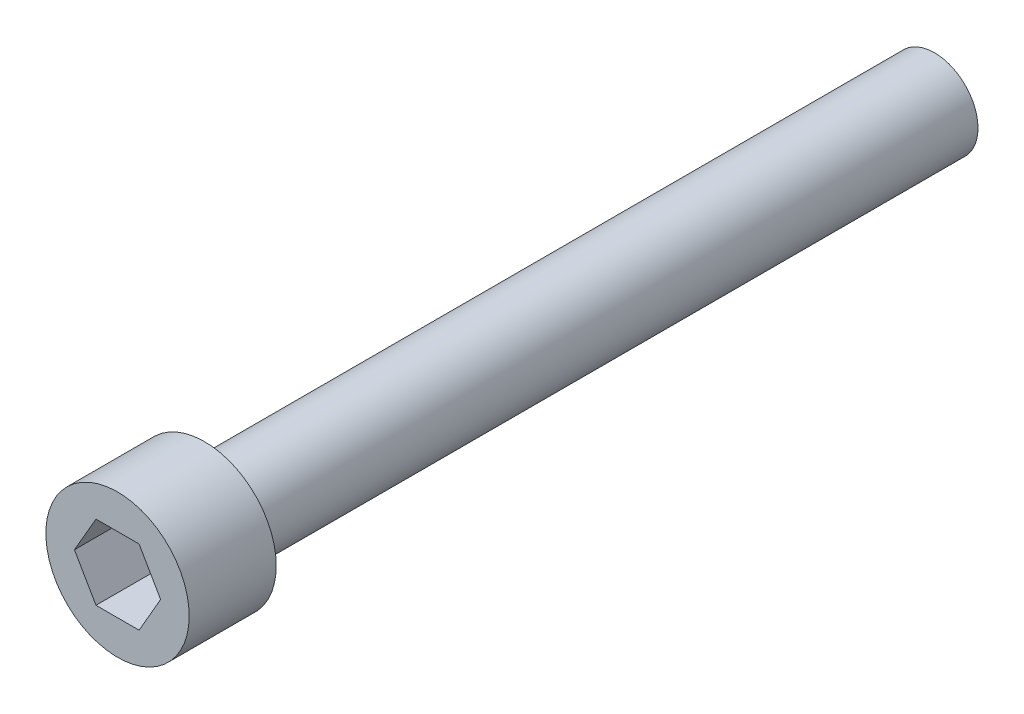
from build123d import *

# Parameters (mm, degrees)
F_9_64_ALLEN_DEPTH = 3.175


with BuildPart() as part:
    # Sketch1 → Revolve1 (revolve)
    with BuildSketch(Plane(origin=(0, 0, 0), x_dir=(1, 0, 0), z_dir=(0, 1, 0))):
        Polygon((0, 0), (0, 39.0906), (2.0828, 39.0906), (2.0828, 4.1656), (3.429, 4.1656), (3.429, 0), align=None)
    revolve(axis=Axis((0, 0, 0), (0, 0, -1)))

    # Sketch2 → 9-64 allen (cut)
    with BuildSketch(Plane.XY):
        Polygon((2.062222993, 0), (1.031111496, 1.7859375), (-1.031111496, 1.7859375), (-2.062222993, 0), (-1.031111496, -1.7859375), (1.031111496, -1.7859375), align=None)
    extrude(amount=-F_9_64_ALLEN_DEPTH, mode=Mode.SUBTRACT)


solid = part.part
